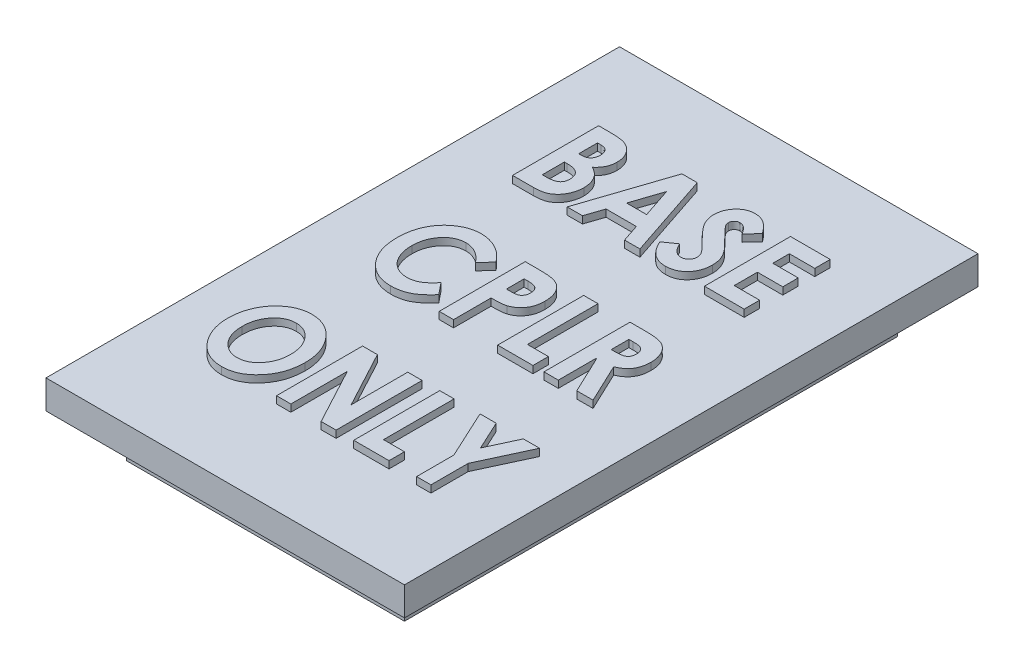
from build123d import *

# Parameters (mm, degrees)
SKETCH1_W           = 19.4
SKETCH1_H           = 34.4
BOSS_EXTRUDE1_DEPTH = 3
SKETCH2_W           = 25
SKETCH2_H           = 40
BOSS_EXTRUDE2_DEPTH = 2
BOSS_EXTRUDE3_DEPTH = 0.5


with BuildPart() as part:
    # Sketch1 → Boss-Extrude1 (new body)
    with BuildSketch(Plane(origin=(0, 0, 0), x_dir=(1, 0, 0), z_dir=(0, 1, 0))):
        Rectangle(SKETCH1_W, SKETCH1_H)
    extrude(amount=BOSS_EXTRUDE1_DEPTH)

    # Sketch2 → Boss-Extrude2 (add)
    with BuildSketch(Plane(origin=(0, 3, 0), x_dir=(1, 0, 0), z_dir=(0, 1, 0))):
        Rectangle(SKETCH2_W, SKETCH2_H)
    extrude(amount=BOSS_EXTRUDE2_DEPTH)

    # Sketch3 → Boss-Extrude3 (add)
    with BuildSketch(Plane(origin=(0, 5, 0), x_dir=(1, 0, 0), z_dir=(0, 1, 0))):
        with BuildLine():
            Line((-7.961538462, 8), (-7.961538462, 14))
            Line((-7.961538462, 14), (-7.152644231, 14))
            add(Edge.make_bspline(
                [(-7.152644231, 14), (-7.096146474, 14.000010014), (-6.986720601, 14.000029408), (-6.828451061, 13.993368156), (-6.681807177, 13.984982859), (-6.546937409, 13.975238121), (-6.424410536, 13.958945153), (-6.313589214, 13.941532651), (-6.214293954, 13.920357194), (-6.15294131, 13.90182965), (-6.123798077, 13.893028846)],
                knots=[0, 0, 0, 0, 0.000169475, 0.000328243, 0.000475119, 0.000610168, 0.000733756, 0.000845793, 0.000946697, 0.001037996, 0.001037996, 0.001037996, 0.001037996], degree=3))
            add(Edge.make_bspline(
                [(-6.123798077, 13.893028846), (-6.085876197, 13.880494701), (-6.010812265, 13.855684164), (-5.903862135, 13.806827036), (-5.802513548, 13.751575497), (-5.70687519, 13.688922299), (-5.617573972, 13.617682565), (-5.534729734, 13.538059019), (-5.457566018, 13.451246983), (-5.386811796, 13.357624626), (-5.32308662, 13.258074118), (-5.267964601, 13.153394885), (-5.220653591, 13.044613639), (-5.182145413, 12.93123), (-5.152365994, 12.813432072), (-5.130215607, 12.691416292), (-5.1187151, 12.564723673), (-5.11650712, 12.478785757), (-5.115384615, 12.435096154)],
                knots=[0, 0, 0, 0, 0.000119741, 0.000237019, 0.000352128, 0.000465803, 0.000579555, 0.000694318, 0.000810103, 0.000927652, 0.001046015, 0.0011643, 0.001282192, 0.00140154, 0.001523101, 0.001646408, 0.001773181, 0.001904279, 0.001904279, 0.001904279, 0.001904279], degree=3))
            add(Edge.make_bspline(
                [(-5.115384615, 12.435096154), (-5.117066766, 12.378927201), (-5.12037478, 12.268468837), (-5.14449192, 12.106685916), (-5.185922945, 11.952932205), (-5.242282774, 11.806016956), (-5.318176825, 11.66516053), (-5.415473506, 11.531029414), (-5.531587814, 11.399383906), (-5.621657352, 11.319952628), (-5.668269231, 11.278846154)],
                knots=[0, 0, 0, 0, 0.000168479, 0.000331321, 0.000489341, 0.00064536, 0.000802389, 0.000967818, 0.001141495, 0.001327778, 0.001327778, 0.001327778, 0.001327778], degree=3))
            add(Edge.make_bspline(
                [(-5.668269231, 11.278846154), (-5.628740078, 11.257270086), (-5.551252974, 11.214975553), (-5.441767028, 11.144961726), (-5.340066458, 11.071326139), (-5.246436492, 10.993889231), (-5.162044069, 10.911183078), (-5.084351357, 10.826074506), (-5.01597209, 10.73571257), (-4.935548916, 10.610109437), (-4.852280174, 10.441187565), (-4.781444486, 10.221852094), (-4.738688032, 9.984827988), (-4.733460985, 9.821095568), (-4.730769231, 9.736778846)],
                knots=[0, 0, 0, 0, 0.000135071, 0.000264773, 0.000389547, 0.000511582, 0.000628879, 0.000743768, 0.000856992, 0.00096835, 0.001190884, 0.001419698, 0.001657818, 0.001910634, 0.001910634, 0.001910634, 0.001910634], degree=3))
            add(Edge.make_bspline(
                [(-4.730769231, 9.736778846), (-4.733517745, 9.654856621), (-4.738930893, 9.493512303), (-4.782526086, 9.257368353), (-4.851899376, 9.031611013), (-4.950612343, 8.82076393), (-5.069416198, 8.627757372), (-5.207190405, 8.45903529), (-5.361523848, 8.316225672), (-5.504459193, 8.218904511), (-5.628264655, 8.153489535), (-5.730960413, 8.114197978), (-5.840189834, 8.076615473), (-5.959380928, 8.050461448), (-6.085889602, 8.02692547), (-6.221673209, 8.011988417), (-6.365239321, 8.002191754), (-6.463924629, 8.000741905), (-6.514423077, 8)],
                knots=[0, 0, 0, 0, 0.000245616, 0.000483736, 0.000717911, 0.000952372, 0.001180171, 0.00139624, 0.001603786, 0.001808809, 0.001913099, 0.002023133, 0.002138298, 0.002259287, 0.002388721, 0.00252424, 0.002668791, 0.002820277, 0.002820277, 0.002820277, 0.002820277], degree=3))
            Line((-6.514423077, 8), (-7.961538462, 8))
        make_face()
        with BuildLine():
            Line((-6.961538462, 12.923076923), (-6.961538462, 11.615384615))
            Line((-6.961538462, 11.615384615), (-6.764423077, 11.615384615))
            add(Edge.make_bspline(
                [(-6.764423077, 11.615384615), (-6.712893238, 11.616950193), (-6.615291209, 11.619915536), (-6.479653541, 11.655524472), (-6.363708755, 11.711840579), (-6.271498574, 11.793962614), (-6.20103877, 11.894961688), (-6.150156455, 12.012586179), (-6.119997342, 12.14673787), (-6.116966927, 12.241425058), (-6.115384615, 12.290865385)],
                knots=[0, 0, 0, 0, 0.000154226, 0.000292118, 0.00041736, 0.000537438, 0.000658158, 0.000784102, 0.000919685, 0.001067834, 0.001067834, 0.001067834, 0.001067834], degree=3))
            add(Edge.make_bspline(
                [(-6.115384615, 12.290865385), (-6.116975633, 12.337129329), (-6.120012855, 12.42544634), (-6.149915697, 12.550121394), (-6.196111845, 12.661073579), (-6.264731022, 12.7548868), (-6.352036252, 12.832115157), (-6.460694466, 12.886672882), (-6.589271015, 12.917536518), (-6.680912716, 12.921155517), (-6.729567308, 12.923076923)],
                knots=[0, 0, 0, 0, 0.000138555, 0.000264499, 0.000382392, 0.000496827, 0.000610121, 0.000728917, 0.000857764, 0.001003598, 0.001003598, 0.001003598, 0.001003598], degree=3))
            Line((-6.729567308, 12.923076923), (-6.961538462, 12.923076923))
        make_face(mode=Mode.SUBTRACT)
        with BuildLine():
            Line((-6.961538462, 10.615384615), (-6.961538462, 9.076923077))
            Line((-6.961538462, 9.076923077), (-6.725961538, 9.076923077))
            add(Edge.make_bspline(
                [(-6.725961538, 9.076923077), (-6.679075661, 9.07727443), (-6.588826034, 9.077950742), (-6.459587988, 9.086091846), (-6.342487339, 9.100679515), (-6.237445003, 9.119169343), (-6.144035861, 9.144344067), (-6.06258387, 9.175110568), (-5.992441432, 9.21090454), (-5.917066361, 9.267433881), (-5.841062789, 9.353924754), (-5.774959904, 9.477499856), (-5.737979149, 9.622536884), (-5.733255208, 9.724950763), (-5.730769231, 9.778846154)],
                knots=[0, 0, 0, 0, 0.000140646, 0.000270726, 0.000388201, 0.000494522, 0.00059045, 0.000677951, 0.000755371, 0.000825804, 0.000959455, 0.001097111, 0.001242588, 0.001404188, 0.001404188, 0.001404188, 0.001404188], degree=3))
            add(Edge.make_bspline(
                [(-5.730769231, 9.778846154), (-5.731445378, 9.81052363), (-5.732759086, 9.872070798), (-5.743424833, 9.961943797), (-5.762955245, 10.046351703), (-5.789049513, 10.125852979), (-5.823118051, 10.19992366), (-5.864209545, 10.26882412), (-5.912605531, 10.333245406), (-5.96935433, 10.392297113), (-6.034681813, 10.445883126), (-6.11007052, 10.491527038), (-6.195144731, 10.530358214), (-6.290603749, 10.560651583), (-6.395217879, 10.586622917), (-6.510064186, 10.602119908), (-6.634379781, 10.613684919), (-6.720721311, 10.614803089), (-6.765625, 10.615384615)],
                knots=[0, 0, 0, 0, 9.502e-05, 0.000184618, 0.000270923, 0.00035454, 0.000435213, 0.000514984, 0.000594793, 0.000676399, 0.000760121, 0.000847523, 0.000940032, 0.001039994, 0.001147565, 0.001262981, 0.001387251, 0.001521914, 0.001521914, 0.001521914, 0.001521914], degree=3))
            Line((-6.765625, 10.615384615), (-6.961538462, 10.615384615))
        make_face(mode=Mode.SUBTRACT)
        Polygon((-2.146634615, 14), (-1.080528846, 14), (0.923076923, 8), (-0.149038462, 8), (-0.558894231, 9.230769231), (-2.673076923, 9.230769231), (-3.084134615, 8), (-4.153846154, 8), align=None)
        Polygon((-1.615384615, 12.390625), (-2.313701923, 10.307692308), (-0.917067308, 10.307692308), align=None, mode=Mode.SUBTRACT)
        with BuildLine():
            Line((4.269230769, 13.198317308), (3.579326923, 12.461538462))
            add(Edge.make_bspline(
                [(3.579326923, 12.461538462), (3.549546393, 12.510055372), (3.492759614, 12.602569477), (3.401176859, 12.727939609), (3.310093587, 12.835082999), (3.217433507, 12.922272252), (3.12453648, 12.990946757), (3.030784751, 13.040284953), (2.93580683, 13.071082956), (2.87160384, 13.075002494), (2.840144231, 13.076923077)],
                knots=[0, 0, 0, 0, 0.000170724, 0.000325543, 0.000465298, 0.000592002, 0.000706438, 0.000810728, 0.000908816, 0.001003058, 0.001003058, 0.001003058, 0.001003058], degree=3))
            add(Edge.make_bspline(
                [(2.840144231, 13.076923077), (2.810738107, 13.075739098), (2.753758866, 13.073444942), (2.672476587, 13.04982776), (2.600276323, 13.010490743), (2.538030421, 12.957738579), (2.488899652, 12.895485632), (2.449218583, 12.829684228), (2.427424095, 12.757748591), (2.424522911, 12.708460207), (2.423076923, 12.683894231)],
                knots=[0, 0, 0, 0, 8.8036e-05, 0.000170585, 0.000251257, 0.000333129, 0.000413469, 0.000488308, 0.000562448, 0.000636119, 0.000636119, 0.000636119, 0.000636119], degree=3))
            add(Edge.make_bspline(
                [(2.423076923, 12.683894231), (2.424449894, 12.658988202), (2.427199556, 12.609108644), (2.442785217, 12.535076307), (2.470943436, 12.463713765), (2.496620595, 12.41917497), (2.509615385, 12.396634615)],
                knots=[0, 0, 0, 0, 7.4761e-05, 0.000149725, 0.000225836, 0.000303822, 0.000303822, 0.000303822, 0.000303822], degree=3))
            add(Edge.make_bspline(
                [(2.509615385, 12.396634615), (2.521362757, 12.379202858), (2.548401734, 12.339080104), (2.601887614, 12.276183606), (2.666874509, 12.197558725), (2.749652145, 12.108609705), (2.843869456, 12.004222931), (2.955700049, 11.889582044), (3.079688137, 11.759206603), (3.16925972, 11.669666198), (3.216346154, 11.622596154)],
                knots=[0, 0, 0, 0, 6.3018e-05, 0.000145049, 0.000247389, 0.000369068, 0.000509426, 0.000669241, 0.000849449, 0.001049175, 0.001049175, 0.001049175, 0.001049175], degree=3))
            add(Edge.make_bspline(
                [(3.216346154, 11.622596154), (3.259962526, 11.578873656), (3.342793618, 11.495841023), (3.461262217, 11.378717023), (3.563874734, 11.271823618), (3.656083735, 11.180869264), (3.731126671, 11.098940107), (3.795535578, 11.032634743), (3.844636867, 10.977184041), (3.872634007, 10.944342851), (3.884615385, 10.930288462)],
                knots=[0, 0, 0, 0, 0.000185276, 0.000351854, 0.000499744, 0.00062978, 0.000740317, 0.00083299, 0.000907052, 0.000962458, 0.000962458, 0.000962458, 0.000962458], degree=3))
            add(Edge.make_bspline(
                [(3.884615385, 10.930288462), (3.930689758, 10.872803883), (4.019724256, 10.76172021), (4.135385777, 10.591373466), (4.229272089, 10.424142373), (4.302594936, 10.258732767), (4.357404984, 10.091551489), (4.39614178, 9.918949423), (4.419270072, 9.739018044), (4.421797199, 9.616253729), (4.423076923, 9.554086538)],
                knots=[0, 0, 0, 0, 0.000220951, 0.000426968, 0.000616906, 0.000795569, 0.000968887, 0.001143841, 0.00132557, 0.001512007, 0.001512007, 0.001512007, 0.001512007], degree=3))
            add(Edge.make_bspline(
                [(4.423076923, 9.554086538), (4.421683676, 9.493525187), (4.418953598, 9.374854752), (4.397748566, 9.200850846), (4.365162242, 9.03479028), (4.31613572, 8.87734385), (4.254962164, 8.727326164), (4.179330434, 8.585481276), (4.089203763, 8.452371248), (3.98799927, 8.327895805), (3.875220873, 8.215145934), (3.753600666, 8.115823534), (3.622955276, 8.032251952), (3.483566814, 7.964752846), (3.336082592, 7.911692343), (3.180302764, 7.873174291), (3.015934993, 7.849820638), (2.903523174, 7.847392861), (2.846153846, 7.846153846)],
                knots=[0, 0, 0, 0, 0.000181634, 0.000355912, 0.000525158, 0.000688637, 0.000849789, 0.001010564, 0.001169908, 0.001331346, 0.001491125, 0.001647491, 0.001801529, 0.001955267, 0.002111147, 0.002270894, 0.002435944, 0.00260797, 0.00260797, 0.00260797, 0.00260797], degree=3))
            add(Edge.make_bspline(
                [(2.846153846, 7.846153846), (2.801242951, 7.847059015), (2.71238807, 7.848849864), (2.581380051, 7.863641431), (2.454733574, 7.887472161), (2.33257414, 7.921437133), (2.214685926, 7.964583914), (2.101237136, 8.017611999), (1.992583246, 8.080799589), (1.887442499, 8.152723679), (1.787408178, 8.236570232), (1.691035736, 8.33063923), (1.598484553, 8.43566571), (1.509072567, 8.551516456), (1.42455804, 8.678997439), (1.342166986, 8.816669303), (1.26420958, 8.965685739), (1.216647513, 9.070274781), (1.192307692, 9.123798077)],
                knots=[0, 0, 0, 0, 0.000134701, 0.000266502, 0.000394973, 0.000520946, 0.00064643, 0.000771176, 0.000896107, 0.00102313, 0.00115286, 0.001287153, 0.001426793, 0.001572479, 0.001725822, 0.001885366, 0.002053639, 0.002230011, 0.002230011, 0.002230011, 0.002230011], degree=3))
            Line((1.192307692, 9.123798077), (2, 9.692307692))
            add(Edge.make_bspline(
                [(2, 9.692307692), (2.029885332, 9.631694792), (2.086826146, 9.516208446), (2.183193909, 9.35922613), (2.282670927, 9.225706885), (2.386172612, 9.115950892), (2.493685872, 9.030389232), (2.604921498, 8.968293231), (2.720711657, 8.930212246), (2.799814332, 8.925438331), (2.838942308, 8.923076923)],
                knots=[0, 0, 0, 0, 0.000202655, 0.000386121, 0.000551746, 0.000701365, 0.000837459, 0.000962256, 0.001081997, 0.001199202, 0.001199202, 0.001199202, 0.001199202], degree=3))
            add(Edge.make_bspline(
                [(2.838942308, 8.923076923), (2.878856236, 8.925007819), (2.956882401, 8.92878245), (3.068026699, 8.962761225), (3.169749476, 9.016496183), (3.256658558, 9.092493313), (3.330005302, 9.180334369), (3.383978934, 9.27763443), (3.416875641, 9.382540163), (3.420990385, 9.454895839), (3.423076923, 9.491586538)],
                knots=[0, 0, 0, 0, 0.000119481, 0.000233569, 0.000345419, 0.000462228, 0.000577494, 0.000687231, 0.000794067, 0.000903976, 0.000903976, 0.000903976, 0.000903976], degree=3))
            add(Edge.make_bspline(
                [(3.423076923, 9.491586538), (3.421192972, 9.525738839), (3.417385092, 9.594768189), (3.394281356, 9.698621147), (3.351745556, 9.800742659), (3.305757467, 9.886409277), (3.258006364, 9.95817764), (3.210503683, 10.01847789), (3.155813764, 10.087801721), (3.088780925, 10.161284965), (3.014506787, 10.243984707), (2.929196653, 10.3318329), (2.835147381, 10.427699994), (2.768182738, 10.492542248), (2.733173077, 10.526442308)],
                knots=[0, 0, 0, 0, 0.000102509, 0.000207194, 0.000317227, 0.000433392, 0.000498396, 0.000575563, 0.000663599, 0.000763214, 0.000873817, 0.000997077, 0.001130512, 0.001276702, 0.001276702, 0.001276702, 0.001276702], degree=3))
            add(Edge.make_bspline(
                [(2.733173077, 10.526442308), (2.667330456, 10.591207064), (2.540492333, 10.715968806), (2.359885906, 10.898020541), (2.19840033, 11.069649127), (2.056844215, 11.231350182), (1.931331216, 11.37940869), (1.824883274, 11.516844152), (1.736820692, 11.642693257), (1.644388208, 11.793147228), (1.556353918, 11.975575746), (1.479131712, 12.19419709), (1.433020351, 12.413543717), (1.426365437, 12.559893195), (1.423076923, 12.632211538)],
                knots=[0, 0, 0, 0, 0.000277069, 0.00053374, 0.000769284, 0.000983887, 0.001178405, 0.001351499, 0.001505204, 0.001638985, 0.001880882, 0.002111232, 0.002333279, 0.002550189, 0.002550189, 0.002550189, 0.002550189], degree=3))
            add(Edge.make_bspline(
                [(1.423076923, 12.632211538), (1.424074589, 12.683560406), (1.42603829, 12.784630126), (1.446283619, 12.933375418), (1.477235726, 13.076572493), (1.520271936, 13.214549021), (1.577718507, 13.346075856), (1.645903361, 13.473011966), (1.728409817, 13.593217855), (1.821390536, 13.706958771), (1.924051507, 13.81022514), (2.03227403, 13.903252135), (2.148450238, 13.979666378), (2.269087662, 14.044492775), (2.396244179, 14.093963938), (2.528925285, 14.128713272), (2.667605366, 14.149643422), (2.761946091, 14.152425979), (2.810096154, 14.153846154)],
                knots=[0, 0, 0, 0, 0.000153963, 0.000303046, 0.000449448, 0.000593137, 0.000735807, 0.000879406, 0.001024754, 0.001172493, 0.001319526, 0.001461108, 0.001599783, 0.001735813, 0.001871295, 0.002008024, 0.002146558, 0.002290969, 0.002290969, 0.002290969, 0.002290969], degree=3))
            add(Edge.make_bspline(
                [(2.810096154, 14.153846154), (2.872390756, 14.151218869), (2.996956736, 14.14596528), (3.180647345, 14.105983832), (3.359767429, 14.041534251), (3.503737275, 13.965914301), (3.61821008, 13.89165202), (3.706117489, 13.823556814), (3.795727531, 13.745035162), (3.88912599, 13.657913665), (3.980658898, 13.557000261), (4.076096126, 13.447588891), (4.173508826, 13.327606301), (4.236710676, 13.242241302), (4.269230769, 13.198317308)],
                knots=[0, 0, 0, 0, 0.000186767, 0.000373464, 0.000561279, 0.000756424, 0.000859769, 0.000970352, 0.00108964, 0.001217168, 0.001353246, 0.001498086, 0.001652761, 0.001816704, 0.001816704, 0.001816704, 0.001816704], degree=3))
        make_face()
        Polygon((5.423076923, 14), (8.192307692, 14), (8.192307692, 12.923076923), (6.423076923, 12.923076923), (6.423076923, 11.769230769), (8.192307692, 11.769230769), (8.192307692, 10.692307692), (6.423076923, 10.692307692), (6.423076923, 9.076923077), (8.192307692, 9.076923077), (8.192307692, 8), (5.423076923, 8), align=None)
        with BuildLine():
            Line((-3.307692308, 2.189903846), (-3.978365385, 1.435096154))
            add(Edge.make_bspline(
                [(-3.978365385, 1.435096154), (-4.035334635, 1.504191785), (-4.14584968, 1.638230883), (-4.325027656, 1.81697071), (-4.510721571, 1.967317808), (-4.700401022, 2.093054232), (-4.898137063, 2.188312825), (-5.10005945, 2.257707655), (-5.307896631, 2.300479795), (-5.448519258, 2.305279031), (-5.519230769, 2.307692308)],
                knots=[0, 0, 0, 0, 0.000268557, 0.000520975, 0.00075768, 0.000984373, 0.001202083, 0.001414174, 0.001623726, 0.001835678, 0.001835678, 0.001835678, 0.001835678], degree=3))
            add(Edge.make_bspline(
                [(-5.519230769, 2.307692308), (-5.578222483, 2.305759441), (-5.694856751, 2.301937913), (-5.866104048, 2.274148484), (-6.029891805, 2.226317713), (-6.187062499, 2.161956059), (-6.335784782, 2.076026702), (-6.478623931, 1.973706841), (-6.613180392, 1.851160642), (-6.739624185, 1.712823221), (-6.854358723, 1.560515442), (-6.955954149, 1.398516346), (-7.039877531, 1.226404408), (-7.11010893, 1.046913811), (-7.164495011, 0.858215021), (-7.201993495, 0.660615171), (-7.227498185, 0.454590236), (-7.229666634, 0.314182152), (-7.230769231, 0.242788462)],
                knots=[0, 0, 0, 0, 0.000176944, 0.000349842, 0.000518736, 0.00068793, 0.000858031, 0.001032823, 0.00121409, 0.001402957, 0.001594304, 0.00178541, 0.001975694, 0.00216787, 0.002363015, 0.002563848, 0.002770778, 0.002984842, 0.002984842, 0.002984842, 0.002984842], degree=3))
            add(Edge.make_bspline(
                [(-7.230769231, 0.242788462), (-7.228626108, 0.144053871), (-7.224440999, -0.048755929), (-7.18033443, -0.328457525), (-7.114223932, -0.592321228), (-7.01832163, -0.837013244), (-6.896544556, -1.060583875), (-6.752207241, -1.260524773), (-6.583921481, -1.434419618), (-6.427041615, -1.55826418), (-6.291594551, -1.641581058), (-6.187647689, -1.69717819), (-6.079770605, -1.743176111), (-5.969321597, -1.77958704), (-5.856960737, -1.811081785), (-5.741257893, -1.830164315), (-5.622971775, -1.844871219), (-5.54291781, -1.84572285), (-5.502403846, -1.846153846)],
                knots=[0, 0, 0, 0, 0.000295969, 0.00057797, 0.000847332, 0.001110704, 0.001364039, 0.001609258, 0.001848114, 0.002087831, 0.002206572, 0.002324856, 0.00244117, 0.002557856, 0.002673603, 0.002790783, 0.002909311, 0.003030758, 0.003030758, 0.003030758, 0.003030758], degree=3))
            add(Edge.make_bspline(
                [(-5.502403846, -1.846153846), (-5.434150648, -1.843799943), (-5.299541704, -1.839157576), (-5.102276443, -1.803652326), (-4.914607741, -1.744335562), (-4.765359021, -1.67530769), (-4.64844638, -1.606784098), (-4.559174681, -1.543990928), (-4.4672333, -1.47269826), (-4.373611742, -1.391815102), (-4.27700047, -1.30156047), (-4.179426368, -1.200316531), (-4.077813021, -1.091399431), (-4.012086688, -1.013516178), (-3.978365385, -0.973557692)],
                knots=[0, 0, 0, 0, 0.00020468, 0.00040367, 0.000599056, 0.000793726, 0.000895557, 0.001005249, 0.001120889, 0.001244477, 0.001376279, 0.00151737, 0.001666219, 0.001823051, 0.001823051, 0.001823051, 0.001823051], degree=3))
            Line((-3.978365385, -0.973557692), (-3.328125, -1.777644231))
            add(Edge.make_bspline(
                [(-3.328125, -1.777644231), (-3.374217131, -1.829676256), (-3.464276532, -1.931341612), (-3.602261554, -2.074042102), (-3.738826475, -2.204483676), (-3.872626043, -2.323389071), (-4.004806739, -2.429601154), (-4.135602437, -2.52250298), (-4.263341417, -2.60470536), (-4.39142039, -2.673883273), (-4.519823168, -2.733447403), (-4.652015653, -2.784129443), (-4.788407037, -2.827409365), (-4.929488689, -2.861798252), (-5.074556396, -2.8902393), (-5.224401802, -2.908502182), (-5.378779169, -2.921452424), (-5.48314473, -2.922530395), (-5.536057692, -2.923076923)],
                knots=[0, 0, 0, 0, 0.000208515, 0.000407418, 0.000595292, 0.000774958, 0.000944271, 0.001103693, 0.001256072, 0.00139967, 0.001540028, 0.001680427, 0.001824116, 0.001968996, 0.002115852, 0.002267318, 0.002421633, 0.002580328, 0.002580328, 0.002580328, 0.002580328], degree=3))
            add(Edge.make_bspline(
                [(-5.536057692, -2.923076923), (-5.632749096, -2.920185239), (-5.822605989, -2.914507318), (-6.100519504, -2.873413315), (-6.364510869, -2.803348876), (-6.615231071, -2.705176051), (-6.853027541, -2.579887902), (-7.076818552, -2.426102541), (-7.285711959, -2.243619365), (-7.48055471, -2.037010024), (-7.656241148, -1.807885372), (-7.811383614, -1.561717323), (-7.941017298, -1.298808074), (-8.047012865, -1.020600636), (-8.130251907, -0.727481208), (-8.188598786, -0.418571738), (-8.223918687, -0.094173419), (-8.228453939, 0.127313379), (-8.230769231, 0.240384615)],
                knots=[0, 0, 0, 0, 0.000290022, 0.000569469, 0.000840603, 0.001107771, 0.001375519, 0.001645227, 0.001920436, 0.002206125, 0.002495811, 0.002785272, 0.003077683, 0.003373669, 0.003677282, 0.00399056, 0.004315751, 0.004654906, 0.004654906, 0.004654906, 0.004654906], degree=3))
            add(Edge.make_bspline(
                [(-8.230769231, 0.240384615), (-8.23008785, 0.314141441), (-8.228738045, 0.460252501), (-8.210710113, 0.675576357), (-8.185225362, 0.885235982), (-8.146196252, 1.087674006), (-8.098185283, 1.284793996), (-8.039895799, 1.475306498), (-7.96936241, 1.659320328), (-7.889030996, 1.836674467), (-7.79952074, 2.007362), (-7.698741796, 2.169069012), (-7.590063734, 2.323144491), (-7.470271339, 2.467358981), (-7.342701871, 2.60392415), (-7.205293927, 2.731583139), (-7.058384965, 2.85034333), (-6.903888864, 2.961023171), (-6.742691468, 3.059949156), (-6.577733074, 3.146852831), (-6.409637203, 3.220870264), (-6.238134473, 3.281157856), (-6.062986851, 3.32621115), (-5.885755528, 3.360889778), (-5.70473925, 3.379845876), (-5.582972164, 3.383017664), (-5.521634615, 3.384615385)],
                knots=[0, 0, 0, 0, 0.000221206, 0.000438206, 0.000647813, 0.000854547, 0.001056273, 0.001256248, 0.001451789, 0.001647052, 0.001840069, 0.002029519, 0.002218283, 0.002405262, 0.002591482, 0.002778581, 0.002967421, 0.00315786, 0.003348334, 0.003534353, 0.0037168, 0.003898878, 0.004079042, 0.004258902, 0.004440213, 0.004624248, 0.004624248, 0.004624248, 0.004624248], degree=3))
            add(Edge.make_bspline(
                [(-5.521634615, 3.384615385), (-5.469515256, 3.383707512), (-5.365478739, 3.38189529), (-5.210172147, 3.366730951), (-5.05616665, 3.343525058), (-4.904136057, 3.307221729), (-4.752593448, 3.265237145), (-4.603860062, 3.210120242), (-4.455802717, 3.147648994), (-4.310403917, 3.074416786), (-4.167306424, 2.992986831), (-4.029420871, 2.902829709), (-3.895979033, 2.80478911), (-3.768162415, 2.69819736), (-3.6449137, 2.583497927), (-3.527120541, 2.46057186), (-3.413657306, 2.329612229), (-3.343246905, 2.236780413), (-3.307692308, 2.189903846)],
                knots=[0, 0, 0, 0, 0.000156324, 0.000312041, 0.000467754, 0.000623156, 0.000780658, 0.000939207, 0.001098606, 0.001262549, 0.001427282, 0.001592301, 0.00175649, 0.001923769, 0.002091302, 0.002261314, 0.002434312, 0.002610777, 0.002610777, 0.002610777, 0.002610777], degree=3))
        make_face()
        with BuildLine():
            Line((-2.307692308, 3.230769231), (-1.262019231, 3.230769231))
            add(Edge.make_bspline(
                [(-1.262019231, 3.230769231), (-1.193902406, 3.230421283), (-1.062419287, 3.229749654), (-0.872369549, 3.221448982), (-0.696831645, 3.206837976), (-0.535854977, 3.18849474), (-0.390271509, 3.163182851), (-0.259271066, 3.13339184), (-0.142704619, 3.09828127), (-0.008348342, 3.041933072), (0.142514233, 2.95578871), (0.302032968, 2.823593291), (0.441640224, 2.66417971), (0.55861731, 2.47798668), (0.654512792, 2.269505168), (0.720532462, 2.038895898), (0.762737699, 1.789208928), (0.767018575, 1.61596708), (0.769230769, 1.526442308)],
                knots=[0, 0, 0, 0, 0.000204341, 0.000394431, 0.000570504, 0.000732705, 0.000880312, 0.001013552, 0.001135587, 0.001244962, 0.001450097, 0.001654159, 0.001863673, 0.002083069, 0.002311656, 0.002549734, 0.00280068, 0.003069034, 0.003069034, 0.003069034, 0.003069034], degree=3))
            add(Edge.make_bspline(
                [(0.769230769, 1.526442308), (0.768249589, 1.476332979), (0.766323012, 1.377941723), (0.752925973, 1.233804755), (0.73134722, 1.096076955), (0.701537344, 0.964546708), (0.662269862, 0.83926178), (0.611961892, 0.721424096), (0.556401328, 0.608659784), (0.489229685, 0.504272563), (0.416546309, 0.405943717), (0.337006677, 0.314966457), (0.249799758, 0.233320947), (0.157074834, 0.158453214), (0.058120208, 0.091075051), (-0.046768484, 0.030448855), (-0.15863329, -0.021434445), (-0.236927464, -0.048726021), (-0.276442308, -0.0625)],
                knots=[0, 0, 0, 0, 0.000150317, 0.000295153, 0.000433869, 0.000568281, 0.000699423, 0.000827104, 0.000952346, 0.001076057, 0.001198894, 0.001318973, 0.001438005, 0.001556826, 0.001676174, 0.00179678, 0.001919929, 0.002045413, 0.002045413, 0.002045413, 0.002045413], degree=3))
            add(Edge.make_bspline(
                [(-0.276442308, -0.0625), (-0.302376343, -0.070151916), (-0.358474514, -0.086703852), (-0.451599846, -0.103467505), (-0.558619291, -0.119062137), (-0.680069356, -0.132334215), (-0.816419275, -0.141390699), (-0.967091813, -0.148409449), (-1.132577146, -0.153587905), (-1.247591739, -0.153757521), (-1.307692308, -0.153846154)],
                knots=[0, 0, 0, 0, 8.1065e-05, 0.000175353, 0.000283459, 0.000405571, 0.000541729, 0.000693343, 0.000858076, 0.001038369, 0.001038369, 0.001038369, 0.001038369], degree=3))
            Line((-1.307692308, -0.153846154), (-1.307692308, -2.769230769))
            Line((-1.307692308, -2.769230769), (-2.307692308, -2.769230769))
            Line((-2.307692308, -2.769230769), (-2.307692308, 3.230769231))
        make_face()
        with BuildLine():
            Line((-1.307692308, 0.923076923), (-1.010817308, 0.923076923))
            add(Edge.make_bspline(
                [(-1.010817308, 0.923076923), (-0.957105938, 0.923530005), (-0.857935032, 0.924366562), (-0.722489597, 0.935999555), (-0.6131833, 0.954045154), (-0.526391328, 0.980037829), (-0.458330247, 1.018847622), (-0.399654428, 1.06446674), (-0.350206115, 1.121550127), (-0.306052623, 1.186158356), (-0.273460637, 1.261531979), (-0.247496103, 1.3434879), (-0.233406564, 1.433414887), (-0.231667531, 1.495548828), (-0.230769231, 1.527644231)],
                knots=[0, 0, 0, 0, 0.000161098, 0.000297446, 0.000407315, 0.000493217, 0.000567464, 0.000641047, 0.00071511, 0.000793114, 0.00087488, 0.00096042, 0.001050524, 0.001146798, 0.001146798, 0.001146798, 0.001146798], degree=3))
            add(Edge.make_bspline(
                [(-0.230769231, 1.527644231), (-0.231570256, 1.555704215), (-0.233120016, 1.609992426), (-0.241932662, 1.688802402), (-0.260781996, 1.761420927), (-0.284266382, 1.828469426), (-0.314214264, 1.890280555), (-0.353896181, 1.944018366), (-0.397514616, 1.9945687), (-0.432962488, 2.021409215), (-0.450721154, 2.034855769)],
                knots=[0, 0, 0, 0, 8.4212e-05, 0.000162926, 0.000237261, 0.000308733, 0.000375922, 0.00044229, 0.000508668, 0.000575307, 0.000575307, 0.000575307, 0.000575307], degree=3))
            add(Edge.make_bspline(
                [(-0.450721154, 2.034855769), (-0.465311388, 2.044485927), (-0.496088033, 2.064799785), (-0.54980836, 2.088207764), (-0.61137481, 2.108567246), (-0.68138594, 2.125139503), (-0.760087535, 2.13817194), (-0.847138798, 2.147848166), (-0.943072566, 2.151935975), (-1.009613929, 2.153189502), (-1.044471154, 2.153846154)],
                knots=[0, 0, 0, 0, 5.2363e-05, 0.000110455, 0.000175068, 0.000246782, 0.000326018, 0.000414284, 0.000509357, 0.000613952, 0.000613952, 0.000613952, 0.000613952], degree=3))
            Line((-1.044471154, 2.153846154), (-1.307692308, 2.153846154))
            Line((-1.307692308, 2.153846154), (-1.307692308, 0.923076923))
        make_face(mode=Mode.SUBTRACT)
        Polygon((1.769230769, 3.230769231), (2.769230769, 3.230769231), (2.769230769, -1.692307692), (4.230769231, -1.692307692), (4.230769231, -2.769230769), (1.769230769, -2.769230769), align=None)
        with BuildLine():
            Line((5, 3.230769231), (6.072115385, 3.230769231))
            add(Edge.make_bspline(
                [(6.072115385, 3.230769231), (6.142639159, 3.230462024), (6.278933856, 3.229868313), (6.475314548, 3.22102825), (6.656196065, 3.208497488), (6.82107935, 3.189527543), (6.969937262, 3.164607467), (7.10311691, 3.134393764), (7.22106282, 3.100882441), (7.355973376, 3.045956859), (7.507180923, 2.959928432), (7.669025771, 2.828556984), (7.810739563, 2.66700772), (7.932430722, 2.479461473), (8.032919784, 2.269052506), (8.103182125, 2.037319407), (8.145904237, 1.787635503), (8.151148578, 1.615159987), (8.153846154, 1.526442308)],
                knots=[0, 0, 0, 0, 0.000211552, 0.000408847, 0.00058962, 0.000755402, 0.000906563, 0.001042146, 0.001164983, 0.001273902, 0.001478441, 0.001684363, 0.001896369, 0.002120391, 0.002353186, 0.002593456, 0.002844601, 0.003110617, 0.003110617, 0.003110617, 0.003110617], degree=3))
            add(Edge.make_bspline(
                [(8.153846154, 1.526442308), (8.153263417, 1.479141612), (8.152120635, 1.386382155), (8.139920365, 1.250237229), (8.119347134, 1.120242418), (8.091841679, 0.995635125), (8.056338776, 0.876823981), (8.010868329, 0.764427204), (7.960123535, 0.657162591), (7.898930745, 0.556711834), (7.83100571, 0.461917278), (7.754118428, 0.373506994), (7.670504193, 0.290192223), (7.576673002, 0.214560323), (7.475854825, 0.14326018), (7.366195934, 0.078865316), (7.249236126, 0.019178098), (7.166938282, -0.01422703), (7.125, -0.03125)],
                knots=[0, 0, 0, 0, 0.000141873, 0.000278221, 0.000409627, 0.000536474, 0.000660808, 0.000781108, 0.00089991, 0.001016373, 0.00113346, 0.001249357, 0.001367494, 0.001487072, 0.001610449, 0.001737632, 0.001868249, 0.002003976, 0.002003976, 0.002003976, 0.002003976], degree=3))
            Line((7.125, -0.03125), (8.423076923, -2.769230769))
            Line((8.423076923, -2.769230769), (7.287259615, -2.769230769))
            Line((7.287259615, -2.769230769), (6.046875, -0.153846154))
            Line((6.046875, -0.153846154), (6, -0.153846154))
            Line((6, -0.153846154), (6, -2.769230769))
            Line((6, -2.769230769), (5, -2.769230769))
            Line((5, -2.769230769), (5, 3.230769231))
        make_face()
        with BuildLine():
            Line((6, 0.923076923), (6.314903846, 0.923076923))
            add(Edge.make_bspline(
                [(6.314903846, 0.923076923), (6.353367504, 0.923658187), (6.427138719, 0.924773021), (6.533171796, 0.929866857), (6.629393859, 0.942293013), (6.716406674, 0.957983066), (6.795004346, 0.975987975), (6.863447706, 1.001787574), (6.923411098, 1.029999332), (6.989583287, 1.075422761), (7.058906544, 1.147373117), (7.11565431, 1.258832648), (7.14902066, 1.392718339), (7.152168914, 1.489372599), (7.153846154, 1.540865385)],
                knots=[0, 0, 0, 0, 0.00011541, 0.000221349, 0.000318252, 0.000406189, 0.000486646, 0.000559658, 0.000625237, 0.000684911, 0.000799674, 0.000920645, 0.001055908, 0.001210134, 0.001210134, 0.001210134, 0.001210134], degree=3))
            add(Edge.make_bspline(
                [(7.153846154, 1.540865385), (7.152666952, 1.5725966), (7.150365833, 1.634517573), (7.133207248, 1.723865704), (7.10573568, 1.807213203), (7.06565578, 1.882345394), (7.017747684, 1.950397248), (6.960966737, 2.008492146), (6.896445677, 2.055989363), (6.820973101, 2.094558615), (6.725432891, 2.122158536), (6.602851531, 2.141329113), (6.449320467, 2.152470172), (6.336558011, 2.153361481), (6.275240385, 2.153846154)],
                knots=[0, 0, 0, 0, 9.5142e-05, 0.000185662, 0.000271941, 0.000357422, 0.000440136, 0.00052088, 0.00059997, 0.000679524, 0.000773812, 0.000896914, 0.001051229, 0.001235158, 0.001235158, 0.001235158, 0.001235158], degree=3))
            Line((6.275240385, 2.153846154), (6, 2.153846154))
            Line((6, 2.153846154), (6, 0.923076923))
        make_face(mode=Mode.SUBTRACT)
        with BuildLine():
            add(Edge.make_bspline(
                [(-6.566105769, -7.384615385), (-6.475779639, -7.387280322), (-6.297669086, -7.392535206), (-6.03555068, -7.437588931), (-5.783038067, -7.509608987), (-5.540048322, -7.611097585), (-5.307638695, -7.742767423), (-5.084446406, -7.901825692), (-4.872297127, -8.091636667), (-4.671226909, -8.305698987), (-4.487362966, -8.541020097), (-4.325528086, -8.791411825), (-4.189574011, -9.05495744), (-4.076292839, -9.329935604), (-3.991992742, -9.619218405), (-3.929120708, -9.920064498), (-3.890976707, -10.234195133), (-3.886760459, -10.44781055), (-3.884615385, -10.556490385)],
                knots=[0, 0, 0, 0, 0.000270817, 0.000534013, 0.000795362, 0.001057196, 0.001321969, 0.001595123, 0.001877797, 0.002174555, 0.002475096, 0.002772484, 0.003067612, 0.003363571, 0.003663238, 0.00397015, 0.004284863, 0.004610806, 0.004610806, 0.004610806, 0.004610806], degree=3))
            add(Edge.make_bspline(
                [(-3.884615385, -10.556490385), (-3.886704299, -10.663983125), (-3.89081724, -10.87562952), (-3.929836927, -11.186206943), (-3.988910442, -11.484891582), (-4.074354909, -11.770762041), (-4.185823654, -12.043636419), (-4.320531712, -12.304238896), (-4.480500864, -12.55164846), (-4.661209762, -12.78439601), (-4.8607566, -12.995287981), (-5.071231945, -13.18240129), (-5.293785292, -13.33921869), (-5.525673548, -13.46947139), (-5.76901791, -13.569920535), (-6.023164945, -13.64091596), (-6.287797259, -13.683953575), (-6.46778875, -13.689500188), (-6.558894231, -13.692307692)],
                knots=[0, 0, 0, 0, 0.00032234, 0.000634666, 0.000937563, 0.001234926, 0.001528205, 0.001820646, 0.002113701, 0.002410868, 0.002703353, 0.002983535, 0.003254317, 0.003518502, 0.003779876, 0.004042052, 0.004308614, 0.004581831, 0.004581831, 0.004581831, 0.004581831], degree=3))
            add(Edge.make_bspline(
                [(-6.558894231, -13.692307692), (-6.654447518, -13.689812432), (-6.842223322, -13.684908892), (-7.116832078, -13.637977635), (-7.380194118, -13.567247676), (-7.629565883, -13.462207083), (-7.867639251, -13.330566219), (-8.091940129, -13.167847474), (-8.304245137, -12.976590856), (-8.502018894, -12.759337121), (-8.68021932, -12.521303037), (-8.839350275, -12.271073374), (-8.971244066, -12.008041739), (-9.080085014, -11.734568596), (-9.165861817, -11.450827666), (-9.225510071, -11.155460225), (-9.262583281, -10.849507579), (-9.266993906, -10.641532797), (-9.269230769, -10.536057692)],
                knots=[0, 0, 0, 0, 0.000286421, 0.000562858, 0.000833462, 0.001102878, 0.001372433, 0.001647964, 0.001932239, 0.002228312, 0.002527832, 0.002823283, 0.003116769, 0.00340915, 0.003705363, 0.004004726, 0.004312136, 0.004628471, 0.004628471, 0.004628471, 0.004628471], degree=3))
            add(Edge.make_bspline(
                [(-9.269230769, -10.536057692), (-9.26801264, -10.465109519), (-9.265593636, -10.324218191), (-9.248175323, -10.115202145), (-9.221178876, -9.910390942), (-9.180899568, -9.710293837), (-9.130636341, -9.514406557), (-9.069261691, -9.322402794), (-8.995859037, -9.13507598), (-8.911499031, -8.952749067), (-8.819170087, -8.776432858), (-8.714502773, -8.610613363), (-8.604492285, -8.452490902), (-8.485138995, -8.304375331), (-8.357100768, -8.16540434), (-8.220655763, -8.035987894), (-8.075289616, -7.916433712), (-7.923260778, -7.806325767), (-7.765737233, -7.706262566), (-7.602584443, -7.621632644), (-7.4379749, -7.546829104), (-7.268918915, -7.488984884), (-7.097918016, -7.440620411), (-6.923124127, -7.409526642), (-6.745764801, -7.387292822), (-6.626273217, -7.385512053), (-6.566105769, -7.384615385)],
                knots=[0, 0, 0, 0, 0.000212825, 0.000422636, 0.000628824, 0.000832248, 0.00103456, 0.001235256, 0.001436581, 0.001637716, 0.00183773, 0.002033168, 0.002225569, 0.002415344, 0.002603324, 0.002792069, 0.002979048, 0.003167535, 0.003354947, 0.003538278, 0.003718527, 0.003896805, 0.004073798, 0.004251072, 0.004428933, 0.004609321, 0.004609321, 0.004609321, 0.004609321], degree=3))
        make_face()
        with BuildLine():
            add(Edge.make_bspline(
                [(-6.580528846, -8.461538462), (-6.639140374, -8.463396255), (-6.754622827, -8.467056672), (-6.923899279, -8.495764438), (-7.086131354, -8.540662184), (-7.240321474, -8.607423768), (-7.388386969, -8.689875092), (-7.529038475, -8.792100967), (-7.66133166, -8.913237664), (-7.785546776, -9.050970647), (-7.899082663, -9.202357575), (-7.998216759, -9.36593544), (-8.082191996, -9.538984799), (-8.151429645, -9.721906985), (-8.203856646, -9.915254685), (-8.242130669, -10.118156161), (-8.265603486, -10.331177977), (-8.268003834, -10.476301169), (-8.269230769, -10.550480769)],
                knots=[0, 0, 0, 0, 0.000175744, 0.000346269, 0.000513677, 0.000679547, 0.000849057, 0.001021196, 0.001199875, 0.001386235, 0.00157686, 0.001766707, 0.00195915, 0.00215314, 0.002352587, 0.002559321, 0.002772089, 0.002994562, 0.002994562, 0.002994562, 0.002994562], degree=3))
            add(Edge.make_bspline(
                [(-8.269230769, -10.550480769), (-8.267463406, -10.632700595), (-8.264003496, -10.793659717), (-8.234689409, -11.028200124), (-8.187131235, -11.249739), (-8.118932904, -11.457519691), (-8.034702749, -11.65370014), (-7.92714603, -11.834339175), (-7.803815548, -12.004190201), (-7.705668616, -12.103727477), (-7.65625, -12.153846154)],
                knots=[0, 0, 0, 0, 0.000246582, 0.000482725, 0.00070787, 0.000925282, 0.001137873, 0.001346897, 0.001554833, 0.001765715, 0.001765715, 0.001765715, 0.001765715], degree=3))
            add(Edge.make_bspline(
                [(-7.65625, -12.153846154), (-7.616453226, -12.190694313), (-7.53817754, -12.263170412), (-7.41122763, -12.356583915), (-7.280892106, -12.436935943), (-7.1455682, -12.502184505), (-7.005776385, -12.552794407), (-6.861653905, -12.589015295), (-6.713437821, -12.611296723), (-6.61305745, -12.614015354), (-6.5625, -12.615384615)],
                knots=[0, 0, 0, 0, 0.000162598, 0.000319811, 0.000471938, 0.000621383, 0.000769664, 0.000917168, 0.001066579, 0.001218193, 0.001218193, 0.001218193, 0.001218193], degree=3))
            add(Edge.make_bspline(
                [(-6.5625, -12.615384615), (-6.505500647, -12.613475929), (-6.392827655, -12.609702948), (-6.226884138, -12.581444864), (-6.067631828, -12.534364526), (-5.914609001, -12.468844749), (-5.768428826, -12.384255066), (-5.629792788, -12.279565199), (-5.497198945, -12.157392947), (-5.371899706, -12.018760387), (-5.257131014, -11.866182102), (-5.157685012, -11.702383861), (-5.072387657, -11.530552201), (-5.00446695, -11.349458169), (-4.949657443, -11.159925811), (-4.911933105, -10.961553296), (-4.888232232, -10.754585857), (-4.885837026, -10.613848434), (-4.884615385, -10.542067308)],
                knots=[0, 0, 0, 0, 0.000170944, 0.000337912, 0.000503345, 0.00066811, 0.000836125, 0.001008722, 0.001188211, 0.001376269, 0.001568577, 0.001760075, 0.001950359, 0.002143225, 0.002339526, 0.002541538, 0.002748332, 0.002963597, 0.002963597, 0.002963597, 0.002963597], degree=3))
            add(Edge.make_bspline(
                [(-4.884615385, -10.542067308), (-4.885720408, -10.47067425), (-4.887893629, -10.330267412), (-4.913363777, -10.124233465), (-4.951059784, -9.926287818), (-5.005254122, -9.736752307), (-5.075517278, -9.556075938), (-5.159371467, -9.382730078), (-5.261337693, -9.219391162), (-5.375720943, -9.064908773), (-5.501662684, -8.924397616), (-5.635878619, -8.801086849), (-5.775275494, -8.694895117), (-5.923624914, -8.610408463), (-6.078421835, -8.543811084), (-6.239946383, -8.495182641), (-6.408487476, -8.467302133), (-6.522736657, -8.463474596), (-6.580528846, -8.461538462)],
                knots=[0, 0, 0, 0, 0.000214064, 0.000420994, 0.000621826, 0.000818127, 0.001011423, 0.001202786, 0.001394913, 0.001588184, 0.001778832, 0.001960019, 0.002134298, 0.002303355, 0.002470803, 0.002638883, 0.002808222, 0.002981566, 0.002981566, 0.002981566, 0.002981566], degree=3))
        make_face(mode=Mode.SUBTRACT)
        Polygon((-2.884615385, -7.538461538), (-1.848557692, -7.538461538), (0.269230769, -11.486778846), (0.269230769, -7.538461538), (1.269230769, -7.538461538), (1.269230769, -13.538461538), (0.227163462, -13.538461538), (-1.884615385, -9.602163462), (-1.884615385, -13.538461538), (-2.884615385, -13.538461538), align=None)
        Polygon((2.5, -7.538461538), (3.5, -7.538461538), (3.5, -12.461538462), (4.961538462, -12.461538462), (4.961538462, -13.538461538), (2.5, -13.538461538), align=None)
        Polygon((5.307692308, -7.538461538), (6.436298077, -7.538461538), (7.384615385, -9.581730769), (8.331730769, -7.538461538), (9.461538462, -7.538461538), (7.884615385, -10.939903846), (7.884615385, -13.538461538), (6.884615385, -13.538461538), (6.884615385, -10.939903846), align=None)
    extrude(amount=BOSS_EXTRUDE3_DEPTH)


solid = part.part
